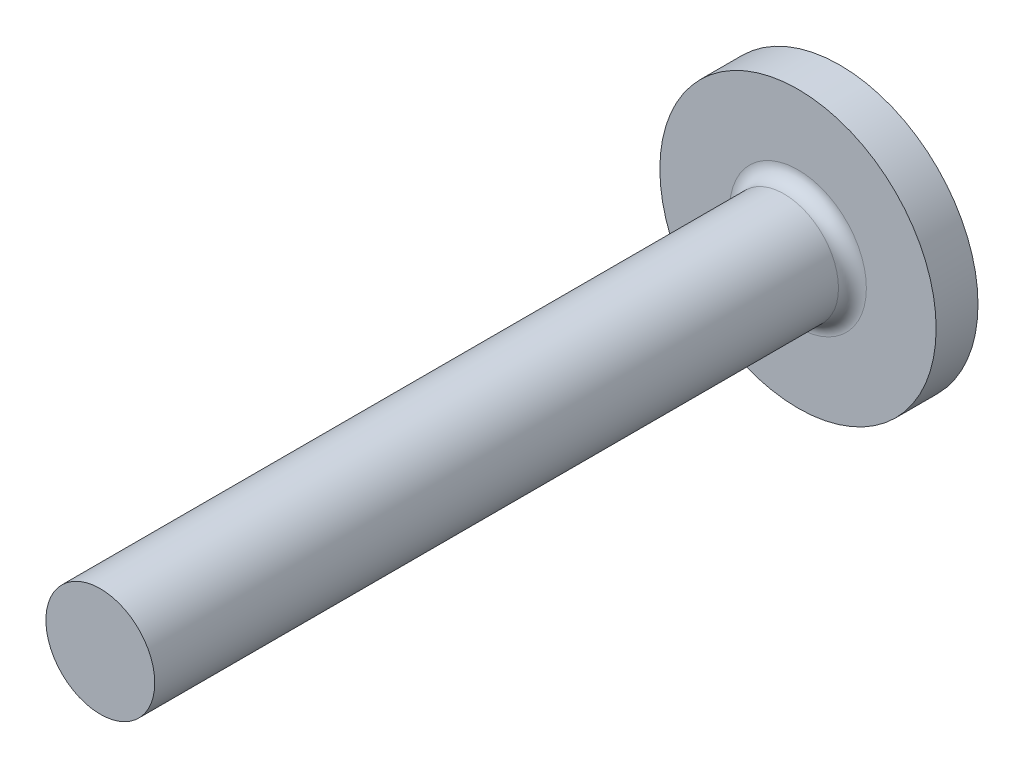
from build123d import *

# Parameters (mm, degrees)
SKETCH1_R           = 3.9
BOSS_EXTRUDE1_DEPTH = 50
SKETCH1_3_R         = 9.9
BOSS_EXTRUDE2_DEPTH = 3
FILLET1_R           = 1


with BuildPart() as part:
    # Sketch1 → Boss-Extrude1 (new body)
    with BuildSketch(Plane.XY):
        Circle(SKETCH1_R)
    extrude(amount=BOSS_EXTRUDE1_DEPTH)

    # Sketch1_3 → Boss-Extrude2 (add)
    with BuildSketch(Plane.XY):
        Circle(SKETCH1_3_R)
    extrude(amount=-BOSS_EXTRUDE2_DEPTH)

    # Fillet1
    fillet1_edges = [part.edges().sort_by_distance(p)[0] for p in [
        (-3.9, 0, 0),
    ]]
    fillet(fillet1_edges, radius=FILLET1_R)


solid = part.part
